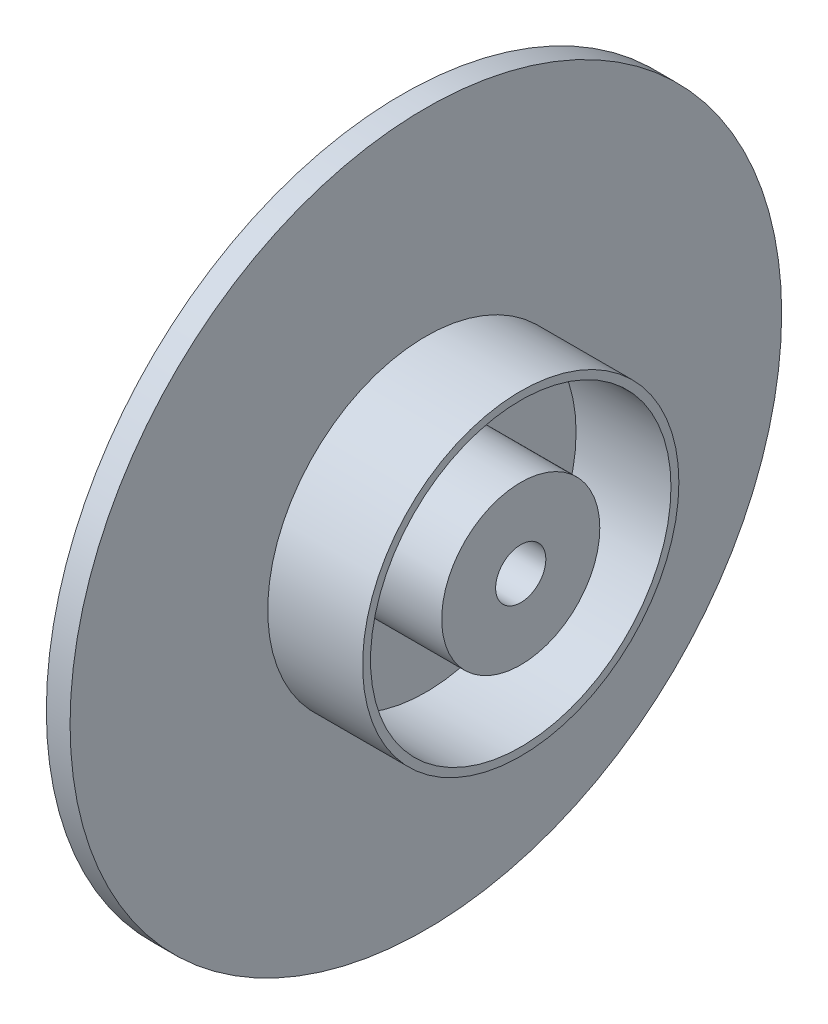
from build123d import *

# Parameters (mm, degrees)
SPROCKET_R                   = 45
ESTRUSIONE_ESTRUSIONE2_DEPTH = 3
SCHIZZO4_R                   = 10
ESTRUSIONE_ESTRUSIONE4_DEPTH = 12
SCHIZZO5_R                   = 20
SCHIZZO5_R_2                 = 19
ESTRUSIONE_ESTRUSIONE5_DEPTH = 12
SCHIZZO6_R                   = 3.175
TAGLIO_ESTRUSIONE1_DEPTH     = 16
SCALE1_SCALE                 = 0.6


with BuildPart() as part:
    # Sprocket → Estrusione-Estrusione2 (new body)
    with BuildSketch(Plane(origin=(0, 0, 0), x_dir=(0, 0, -1), z_dir=(1, 0, 0))):
        Circle(SPROCKET_R)
    extrude(amount=ESTRUSIONE_ESTRUSIONE2_DEPTH)

    # Schizzo4 → Estrusione-Estrusione4 (add)
    with BuildSketch(Plane(origin=(3, 0, 0), x_dir=(0, 0, -1), z_dir=(1, 0, 0))):
        Circle(SCHIZZO4_R)
    extrude(amount=ESTRUSIONE_ESTRUSIONE4_DEPTH)

    # Schizzo5 → Estrusione-Estrusione5 (add)
    with BuildSketch(Plane(origin=(3, 0, 0), x_dir=(0, 0, -1), z_dir=(1, 0, 0))):
        Circle(SCHIZZO5_R)
        Circle(SCHIZZO5_R_2, mode=Mode.SUBTRACT)
    extrude(amount=ESTRUSIONE_ESTRUSIONE5_DEPTH)

    # Schizzo6 → Taglio-Estrusione1 (cut, through all)
    with BuildSketch(Plane(origin=(15, 0, 0), x_dir=(0, 0, -1), z_dir=(1, 0, 0))):
        Circle(SCHIZZO6_R)
    extrude(amount=-TAGLIO_ESTRUSIONE1_DEPTH, mode=Mode.SUBTRACT)


with BuildPart() as part_1:
    # Scale1: scaled about (3.02832768, 0, 0)
    add(part.part.scale(SCALE1_SCALE).moved(Location((1.211331072, 0, 0))))


solid = part_1.part
